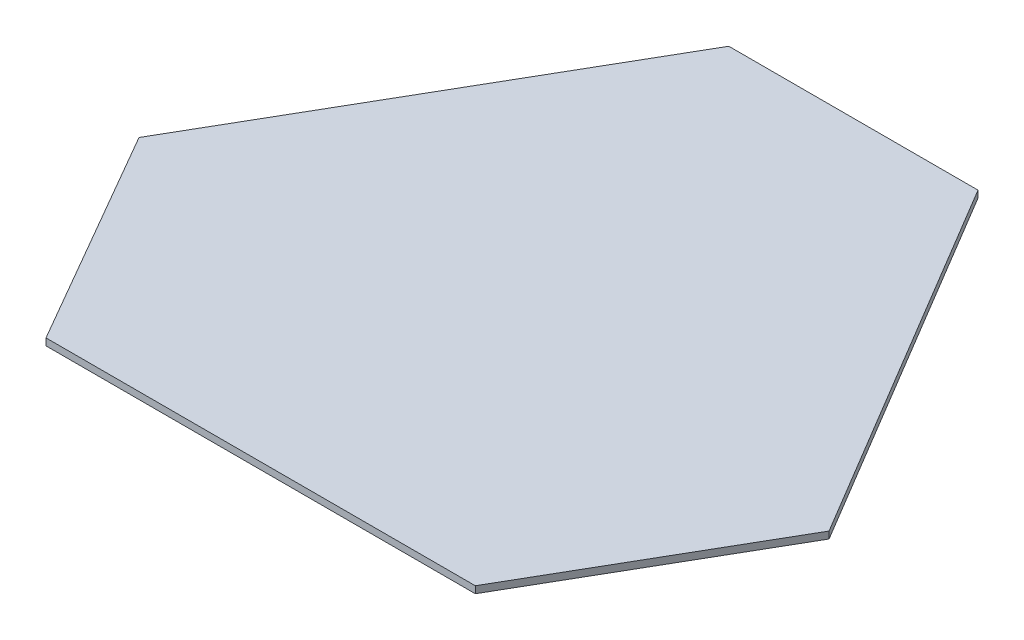
from build123d import *

# Parameters (mm, degrees)
BOSS_EXTRUDE1_DEPTH = 3


with BuildPart() as part:
    # Sketch2 → Boss-Extrude1 (new body)
    with BuildSketch(Plane(origin=(0, 0, 0), x_dir=(1, 0, 0), z_dir=(0, 1, 0))):
        Polygon((-56.681690491, 106.813901532), (51.068521848, 106.813901532), (146.519703864, -53.031945828), (90.535171685, -150), (-95.093627324, -150), (-150.023446498, -54.85876234), align=None)
    extrude(amount=BOSS_EXTRUDE1_DEPTH)


solid = part.part
